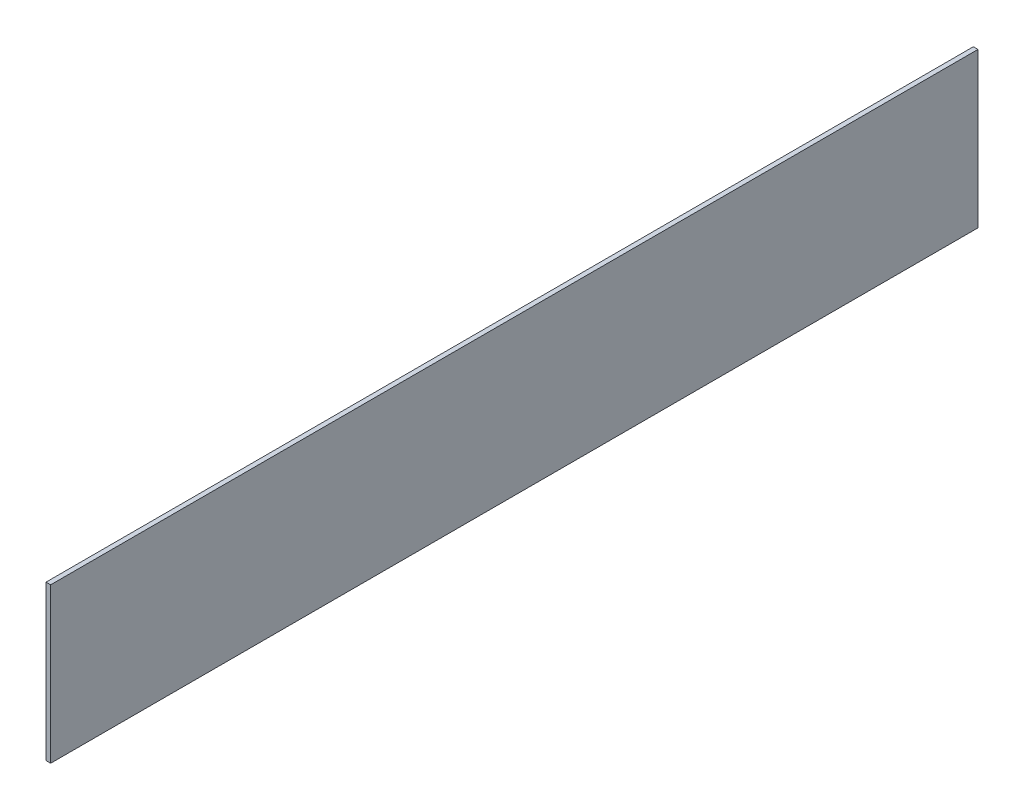
from build123d import *

# Parameters (mm, degrees)
SKETCH1_W           = 600
SKETCH1_H           = 100
BOSS_EXTRUDE1_DEPTH = 3


with BuildPart() as part:
    # Sketch1 → Boss-Extrude1 (new body)
    with BuildSketch(Plane(origin=(1495.226005682, 0, 0), x_dir=(0, 0, -1), z_dir=(1, 0, 0))):
        with Locations((-276.453821887, 50)):
            Rectangle(SKETCH1_W, SKETCH1_H)
    extrude(amount=BOSS_EXTRUDE1_DEPTH)


solid = part.part
